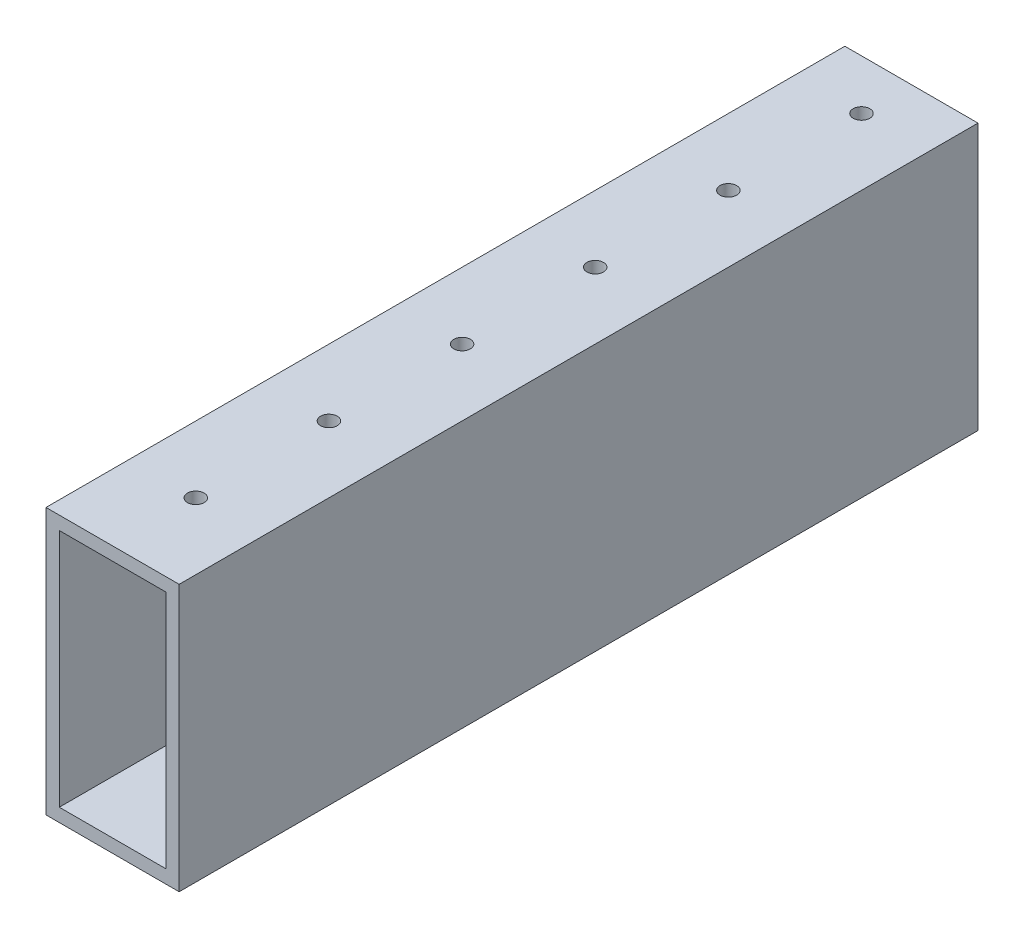
from build123d import *

# Parameters (mm, degrees)
SKETCH1_W           = 25.4
SKETCH1_H           = 50.8
SKETCH1_W_2         = 20.32
SKETCH1_H_2         = 45.72
EXTRUDE_THIN1_DEPTH = 152.4
SKETCH2_R           = 1.5875
CUT_EXTRUDE1_DEPTH  = 51.8
LPATTERN1_COUNT     = 50
LPATTERN1_PITCH     = 25.4


with BuildPart() as part:
    # Sketch1 → Extrude-Thin1 (new body)
    with BuildSketch(Plane.XY):
        with Locations((12.7, 25.4)):
            Rectangle(SKETCH1_W, SKETCH1_H)
        with Locations((12.7, 25.4)):
            Rectangle(SKETCH1_W_2, SKETCH1_H_2, mode=Mode.SUBTRACT)
    extrude(amount=EXTRUDE_THIN1_DEPTH)

    # Sketch2 → Cut-Extrude1 (cut, through all)
    with BuildSketch(Plane(origin=(0, 50.8, 0), x_dir=(1, 0, 0), z_dir=(0, 1, 0))):
        with Locations((12.7, -136.525)):
            Circle(SKETCH2_R)
    cut_extrude1 = extrude(amount=-CUT_EXTRUDE1_DEPTH, mode=Mode.SUBTRACT)

    # LPattern1: Cut-Extrude1 ×50
    with Locations(*[(0, 0, -i * LPATTERN1_PITCH) for i in range(1, LPATTERN1_COUNT)]):
        add(cut_extrude1, mode=Mode.SUBTRACT)


solid = part.part
